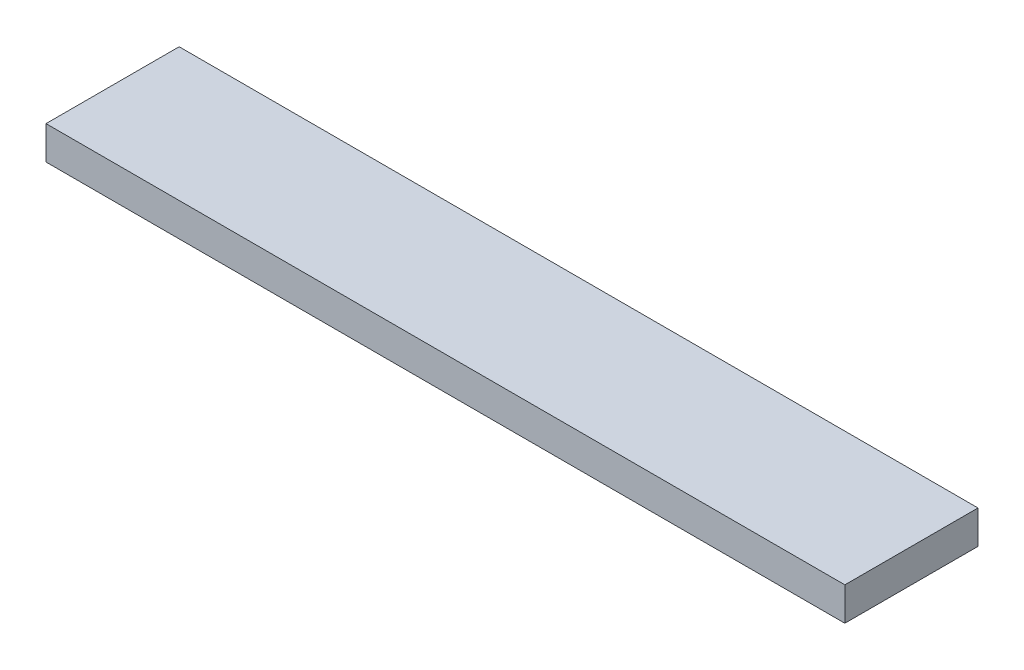
from build123d import *

# Parameters (mm, degrees)
SKETCH1_W           = 76.2
SKETCH1_H           = 12.7
BOSS_EXTRUDE1_DEPTH = 3.175


with BuildPart() as part:
    # Sketch1 → Boss-Extrude1 (new body)
    with BuildSketch(Plane(origin=(0, 0, 0), x_dir=(1, 0, 0), z_dir=(0, 1, 0))):
        with Locations((38.1, -6.35)):
            Rectangle(SKETCH1_W, SKETCH1_H)
    extrude(amount=BOSS_EXTRUDE1_DEPTH)


solid = part.part
